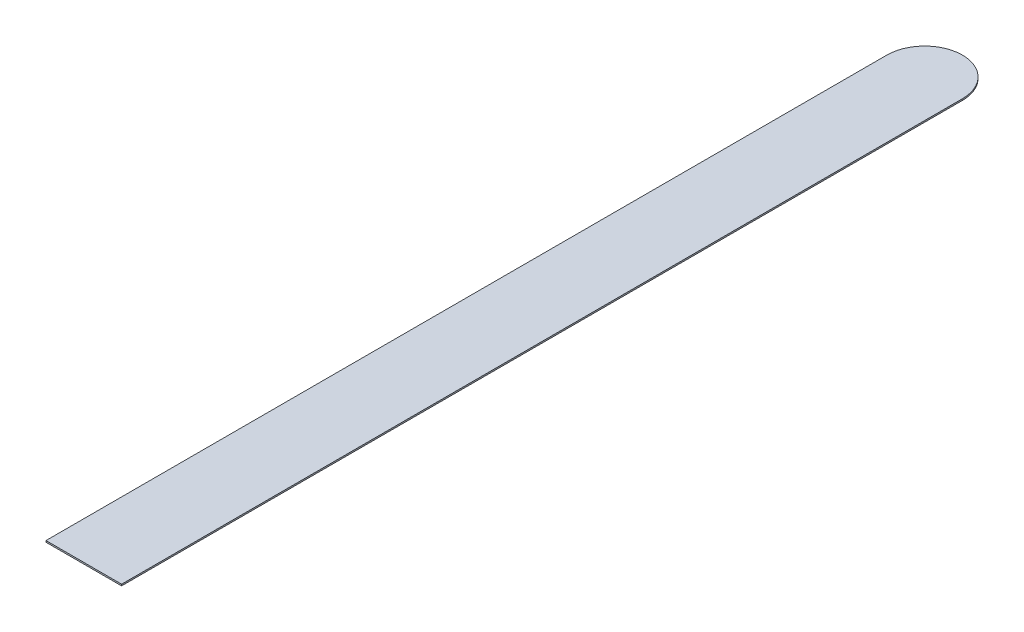
from build123d import *

# Parameters (mm, degrees)
BOSS_EXTRUDE1_DEPTH = 0.127


with BuildPart() as part:
    # Sketch1 → Boss-Extrude1 (new body)
    with BuildSketch(Plane(origin=(0, 0, 0), x_dir=(1, 0, 0), z_dir=(0, 1, 0))):
        with BuildLine():
            Line((0, 0), (6.35, 0))
            Line((6.35, 0), (6.35, 70.6374))
            ThreePointArc((6.35, 70.6374), (3.175, 73.8124), (0, 70.6374))
            Line((0, 70.6374), (0, 0))
        make_face()
    extrude(amount=BOSS_EXTRUDE1_DEPTH)


solid = part.part
